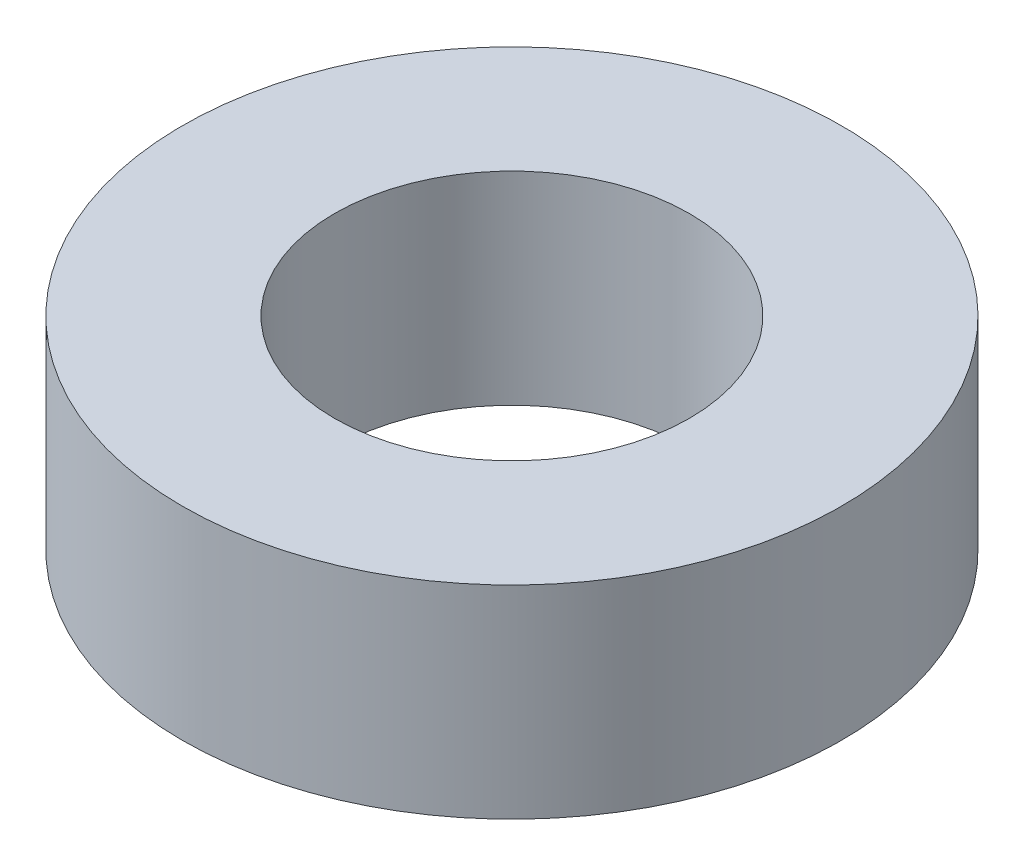
from build123d import *

# Parameters (mm, degrees)
SKETCH1_R           = 6.5
SKETCH1_R_2         = 3.5
BOSS_EXTRUDE1_DEPTH = 4


with BuildPart() as part:
    # Sketch1 → Boss-Extrude1 (new body)
    with BuildSketch(Plane(origin=(0, 0, 0), x_dir=(1, 0, 0), z_dir=(0, 1, 0))):
        Circle(SKETCH1_R)
        Circle(SKETCH1_R_2, mode=Mode.SUBTRACT)
    extrude(amount=BOSS_EXTRUDE1_DEPTH)


solid = part.part
